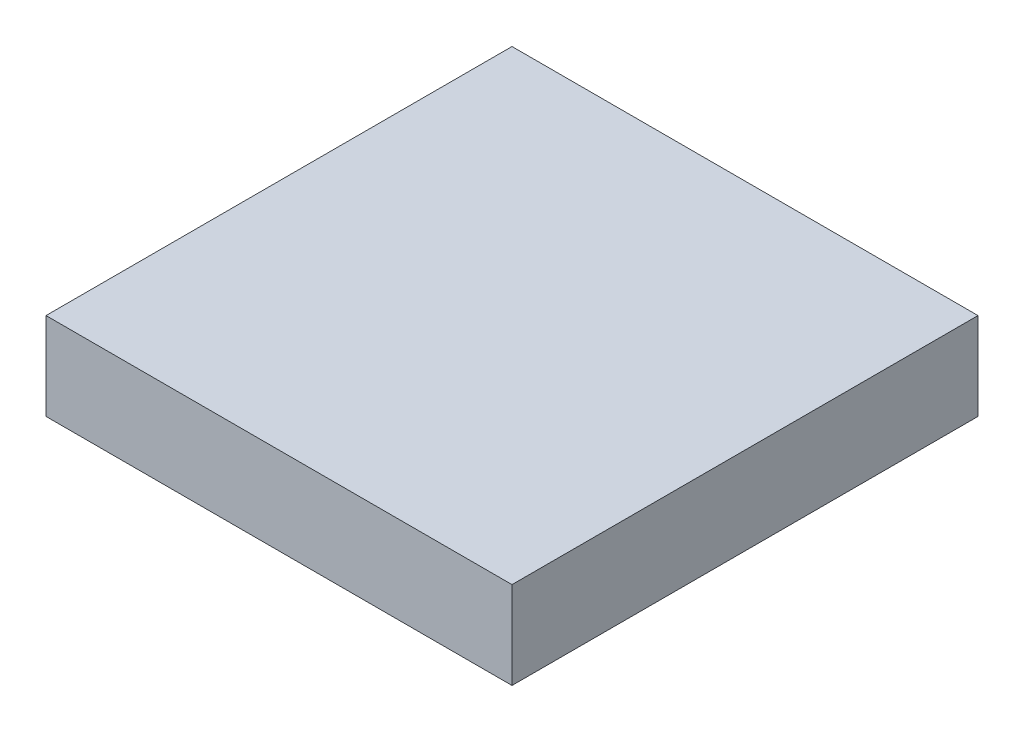
from build123d import *

# Parameters (mm, degrees)
SKETCH1_W           = 203.2
SKETCH1_H           = 38.1
BOSS_EXTRUDE1_DEPTH = 203.2


with BuildPart() as part:
    # Sketch1 → Boss-Extrude1 (new body)
    with BuildSketch(Plane.XY):
        Rectangle(SKETCH1_W, SKETCH1_H)
    extrude(amount=BOSS_EXTRUDE1_DEPTH)


solid = part.part
